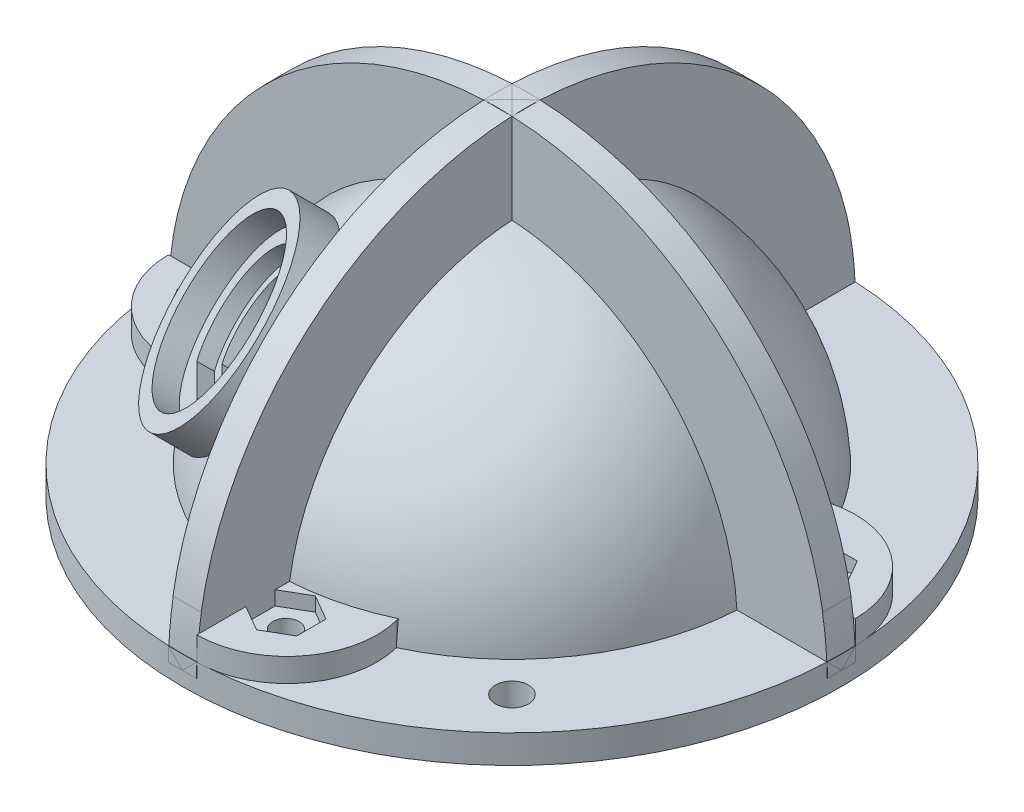
from build123d import *

# Parameters (mm, degrees)
BOSS_EXTRUDE1_DEPTH      = 1.5
BOSS_EXTRUDE1_DEPTH_BACK = 1.5
BOSS_EXTRUDE2_DEPTH      = 1.5
BOSS_EXTRUDE2_DEPTH_BACK = 1.5
SKETCH6_W                = 9.75
SKETCH6_H                = 3
SKETCH6_W_2              = 0.965
SKETCH6_H_2              = 1.5
BOSS_EXTRUDE4_DEPTH      = 2.5
CUT_EXTRUDE1_DEPTH       = 1.5
SKETCH11_R               = 1.4
CUT_EXTRUDE2_DEPTH       = 5
SKETCH13_R               = 10.5
BOSS_EXTRUDE5_DEPTH      = 2
BOSS_EXTRUDE5_DEPTH_BACK = 5
CUT_EXTRUDE3_DEPTH       = 10
CUT_EXTRUDE3_DEPTH_BACK  = 10
SKETCH15_R               = 9
CUT_EXTRUDE4_DEPTH       = 10
CUT_EXTRUDE5_DEPTH       = 4.1
SKETCH19_R               = 8.75
CUT_EXTRUDE6_DEPTH       = 2.5
SKETCH23_R               = 1.75
CUT_EXTRUDE9_DEPTH       = 10


with BuildPart() as part:
    # Sketch1 → Revolve1 (revolve)
    with BuildSketch(Plane.XY):
        with BuildLine():
            Line((-20.885, 0), (-20.885, 11.793939121))
            ThreePointArc((-20.885, 11.793939121), (-12.091372858, 20.714220415), (0, 23.985))
            Line((0, 23.985), (0, 25.485))
            ThreePointArc((0, 25.485), (-18.020616319, 18.020616319), (-25.485, 0))
            Line((-25.485, 0), (-24.285, 0))
            Line((-24.285, 0), (-24.285, 0.5))
            Line((-24.285, 0.5), (-22.085, 0.5))
            Line((-22.085, 0.5), (-22.085, 0))
            Line((-22.085, 0), (-20.885, 0))
        make_face()
    revolve(axis=Axis((0, 0, 0), (0, 1, 0)))



with BuildPart() as body_2:
    # Sketch2 → Boss-Extrude1 (new body, two sides)
    with BuildSketch(Plane.XY) as boss_extrude1_sk:
        with BuildLine():
            Line((-24.9, 0), (-35, 0))
            ThreePointArc((-35, 0), (0, 35), (35, 0))
            Line((35, 0), (24.9, 0))
            ThreePointArc((24.9, 0), (0, 24.9), (-24.9, 0))
        make_face()
    extrude(amount=BOSS_EXTRUDE1_DEPTH)
    extrude(boss_extrude1_sk.sketch, amount=-BOSS_EXTRUDE1_DEPTH_BACK)

    # Sketch3 → Boss-Extrude2 (add, two sides)
    with BuildSketch(Plane(origin=(0, 0, 0), x_dir=(0, 0, -1), z_dir=(1, 0, 0))) as boss_extrude2_sk:
        with BuildLine():
            Line((35, 0), (24.9, 0))
            ThreePointArc((24.9, 0), (0, 24.9), (-24.9, 0))
            Line((-24.9, 0), (-35, 0))
            ThreePointArc((-35, 0), (0, 35), (35, 0))
        make_face()
    extrude(amount=BOSS_EXTRUDE2_DEPTH)
    extrude(boss_extrude2_sk.sketch, amount=-BOSS_EXTRUDE2_DEPTH_BACK)


with BuildPart() as part_1:
    add(part.part)

    add(body_2.part)  # Revolve3 merges body 2
    # Sketch6 → Revolve3 (revolve)
    with BuildSketch(Plane(origin=(0, 0, 0), x_dir=(0, 0, -1), z_dir=(1, 0, 0))):
        with Locations((30.125, 0)):
            Rectangle(SKETCH6_W, SKETCH6_H)
        with Locations((24.7675, 0.75)):
            Rectangle(SKETCH6_W_2, SKETCH6_H_2)
    revolve(axis=Axis((0, 0, 0), (0, -1, 0)))

    # Sketch9 → Cut-Revolve1 (revolve, cut)
    with BuildSketch(Plane.XY):
        with BuildLine():
            Line((34.507469645, 5.851028856), (35.470882951, 5.851028856))
            Line((35.470882951, 5.851028856), (35.470882951, 1.5))
            Line((35.470882951, 1.5), (34.96784237, 1.5))
            ThreePointArc((34.96784237, 1.5), (34.805712289, 3.682715312), (34.507469645, 5.851028856))
        make_face()
    revolve(axis=Axis((0, 0, 0), (0, 1, 0)), mode=Mode.SUBTRACT)

    # Sketch7 → Boss-Extrude4 (add)
    with BuildSketch(Plane(origin=(0, 1.5, 0), x_dir=(1, 0, 0), z_dir=(0, 1, 0))):
        with BuildLine():
            Line((23.044996888, 10.777909974), (22.609782845, 10.667601403))
            ThreePointArc((22.609782845, 10.667601403), (24.220082694, 6.195772291), (24.954959427, 1.5))
            Line((24.954959427, 1.5), (25.396559314, 1.5))
            Line((25.396559314, 1.5), (34.96784237, 1.5))
            ThreePointArc((34.96784237, 1.5), (31.274568745, 9.053705347), (23.044996888, 10.777909974))
        make_face()
        with BuildLine():
            ThreePointArc((10.667601403, -22.609782845), (6.195772291, -24.220082694), (1.5, -24.954959427))
            Line((1.5, -24.954959427), (1.5, -25.396559314))
            Line((1.5, -25.396559314), (1.5, -34.96784237))
            ThreePointArc((1.5, -34.96784237), (9.053705347, -31.274568745), (10.777909974, -23.044996888))
            Line((10.777909974, -23.044996888), (10.667601403, -22.609782845))
        make_face()
        with BuildLine():
            Line((-25.396559314, -1.5), (-34.96784237, -1.5))
            ThreePointArc((-34.96784237, -1.5), (-31.274568745, -9.053705347), (-23.044996888, -10.777909974))
            Line((-23.044996888, -10.777909974), (-22.609782845, -10.667601403))
            ThreePointArc((-22.609782845, -10.667601403), (-24.220082694, -6.195772291), (-24.954959427, -1.5))
            Line((-24.954959427, -1.5), (-25.396559314, -1.5))
        make_face()
        with BuildLine():
            ThreePointArc((-2.626689255, 34.901296588), (-9.387133949, 30.818973666), (-10.777909974, 23.044996888))
            ThreePointArc((-10.777909974, 23.044996888), (-6.25053836, 24.661021779), (-1.5, 25.396559314))
            Line((-1.5, 25.396559314), (-1.5, 34.96784237))
            ThreePointArc((-1.5, 34.96784237), (-2.063612885, 34.939111349), (-2.626689255, 34.901296588))
        make_face()
        with BuildLine():
            Line((-10.777909974, 23.044996888), (-10.667601403, 22.609782845))
            ThreePointArc((-10.667601403, 22.609782845), (-6.195772291, 24.220082694), (-1.5, 24.954959427))
            Line((-1.5, 24.954959427), (-1.5, 25.396559314))
            ThreePointArc((-1.5, 25.396559314), (-6.25053836, 24.661021779), (-10.777909974, 23.044996888))
        make_face()
    extrude(amount=BOSS_EXTRUDE4_DEPTH)

    # Sketch10 → Cut-Extrude1 (cut)
    with BuildSketch(Plane(origin=(0, 4, 0), x_dir=(1, 0, 0), z_dir=(0, 1, 0))):
        Polygon((4.2, -31.327119097), (6.9, -29.76827337), (6.9, -26.650581916), (4.2, -25.091736189), (1.5, -26.650581916), (1.5, -29.76827337), align=None)
        Polygon((-25.091736189, -4.2), (-26.650581916, -1.5), (-29.76827337, -1.5), (-31.327119097, -4.2), (-29.76827337, -6.9), (-26.650581916, -6.9), align=None)
        Polygon((-4.2, 31.327119097), (-6.9, 29.76827337), (-6.9, 26.650581916), (-4.2, 25.091736189), (-1.5, 26.650581916), (-1.5, 29.76827337), align=None)
        Polygon((31.327119097, 4.2), (29.76827337, 6.9), (26.650581916, 6.9), (25.091736189, 4.2), (26.650581916, 1.5), (29.76827337, 1.5), align=None)
    extrude(amount=-CUT_EXTRUDE1_DEPTH, mode=Mode.SUBTRACT)

    # Sketch11 → Cut-Extrude2 (cut, through all)
    with BuildSketch(Plane(origin=(0, 2.5, 0), x_dir=(1, 0, 0), z_dir=(0, 1, 0))):
        with Locations((28.209427643, 4.2)):
            Circle(SKETCH11_R)
        with Locations((4.2, -28.209427643)):
            Circle(SKETCH11_R)
        with Locations((-28.209427643, -4.2)):
            Circle(SKETCH11_R)
        with Locations((-4.2, 28.209427643)):
            Circle(SKETCH11_R)
    extrude(amount=-CUT_EXTRUDE2_DEPTH, mode=Mode.SUBTRACT)

    # Sketch13 → Boss-Extrude5 (add, two sides)
    with BuildSketch(Plane(origin=(-12.655947457, 12.655947457, 12.655947457), x_dir=(-0.816496581, -0.40824829, -0.40824829), z_dir=(0.577350269, -0.577350269, -0.577350269))) as boss_extrude5_sk:
        Circle(SKETCH13_R)
    extrude(amount=BOSS_EXTRUDE5_DEPTH)
    extrude(boss_extrude5_sk.sketch, amount=-BOSS_EXTRUDE5_DEPTH_BACK)

    # Sketch12 → Cut-Extrude3 (cut, two sides)
    with BuildSketch(Plane(origin=(-12.655947457, 12.655947457, 12.655947457), x_dir=(-0.816496581, -0.40824829, -0.40824829), z_dir=(0.577350269, -0.577350269, -0.577350269))) as cut_extrude3_sk:
        with BuildLine():
            ThreePointArc((-5.097893803, 3.349847575), (-5.282754963, -3.05), (0.352106197, -6.089829327))
            Line((0.352106197, -6.089829327), (5.097893803, -3.349847575))
            ThreePointArc((5.097893803, -3.349847575), (5.282754963, 3.05), (-0.352106197, 6.089829327))
            Line((-0.352106197, 6.089829327), (-5.097893803, 3.349847575))
        make_face()
    extrude(amount=CUT_EXTRUDE3_DEPTH, mode=Mode.SUBTRACT)
    extrude(cut_extrude3_sk.sketch, amount=-CUT_EXTRUDE3_DEPTH_BACK, mode=Mode.SUBTRACT)

    # Sketch15 → Cut-Extrude4 (cut)
    with BuildSketch(Plane(origin=(-11.501246918, 11.501246918, 11.501246918), x_dir=(-0.40824829, 0.40824829, -0.816496581), z_dir=(0.577350269, -0.577350269, -0.577350269))):
        Circle(SKETCH15_R)
    extrude(amount=CUT_EXTRUDE4_DEPTH, mode=Mode.SUBTRACT)

    # Sketch18 → Cut-Extrude5 (cut)
    with BuildSketch(Plane(origin=(-15.542698803, 15.542698803, 15.542698803), x_dir=(0.40824829, -0.40824829, 0.816496581), z_dir=(-0.577350269, 0.577350269, 0.577350269))):
        with BuildLine():
            Line((0.654858953, -7.06973548), (5.795141047, -4.101992229))
            ThreePointArc((5.795141047, -4.101992229), (6.148780367, 3.55), (-0.654858953, 7.06973548))
            ThreePointArc((-0.654858953, 7.06973548), (-3.55, 6.148780367), (-5.795141047, 4.101992229))
            ThreePointArc((-5.795141047, 4.101992229), (-6.148780367, -3.55), (0.654858953, -7.06973548))
        make_face()
    extrude(amount=-CUT_EXTRUDE5_DEPTH, mode=Mode.SUBTRACT)

    # Sketch19 → Cut-Extrude6 (cut)
    with BuildSketch(Plane(origin=(-15.542698803, 15.542698803, 15.542698803), x_dir=(0.40824829, -0.40824829, 0.816496581), z_dir=(-0.577350269, 0.577350269, 0.577350269))):
        Circle(SKETCH19_R)
    extrude(amount=-CUT_EXTRUDE6_DEPTH, mode=Mode.SUBTRACT)

    # Sketch23 → Cut-Extrude9 (cut)
    with BuildSketch(Plane(origin=(0, 1.5, 0), x_dir=(1, 0, 0), z_dir=(0, 1, 0))):
        with Locations((21.213203436, -21.213203436)):
            Circle(SKETCH23_R)
        with Locations((-21.213203436, 21.213203436)):
            Circle(SKETCH23_R)
    extrude(amount=-CUT_EXTRUDE9_DEPTH, mode=Mode.SUBTRACT)


solid = part_1.part
